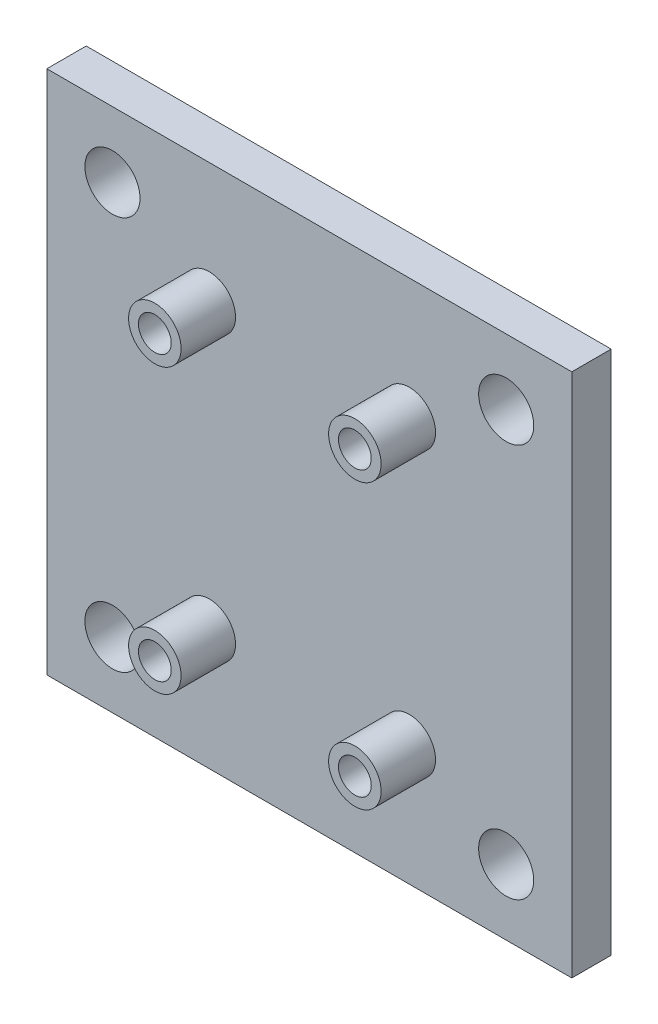
from build123d import *

# Parameters (mm, degrees)
SKETCH_1_W          = 40
SKETCH_1_H          = 40
EXTRUDE_1_DEPTH     = 3
SKETCH_2_R          = 2
EXTRUDE_2_DEPTH     = 4.15
SKETCH_4_R          = 2.1
CUT_EXTRUDE_1_DEPTH = 4
SKETCH_3_R          = 1.25
CUT_EXTRUDE_2_DEPTH = 4.15


with BuildPart() as part:
    # 草圖1 → 填料-伸長1 (new body)
    with BuildSketch(Plane.XY):
        Rectangle(SKETCH_1_W, SKETCH_1_H)
    extrude(amount=EXTRUDE_1_DEPTH)

    # 草圖2 → 填料-伸長2 (add)
    with BuildSketch(Plane.XY.offset(3)):
        with Locations((-7.62, 10.795)):
            Circle(SKETCH_2_R)
        with Locations((-7.62, -10.795)):
            Circle(SKETCH_2_R)
        with Locations((7.62, -10.795)):
            Circle(SKETCH_2_R)
        with Locations((7.62, 10.795)):
            Circle(SKETCH_2_R)
    extrude(amount=EXTRUDE_2_DEPTH)

    # 草圖4 → 除料-伸長1 (cut, through all)
    with BuildSketch(Plane.XY.offset(3)):
        with Locations((-15, 15)):
            Circle(SKETCH_4_R)
        with Locations((-15, -15)):
            Circle(SKETCH_4_R)
        with Locations((15, -15)):
            Circle(SKETCH_4_R)
        with Locations((15, 15)):
            Circle(SKETCH_4_R)
    extrude(amount=-CUT_EXTRUDE_1_DEPTH, mode=Mode.SUBTRACT)

    # 草圖3 → 除料-伸長2 (cut)
    with BuildSketch(Plane.XY.offset(7.15)):
        with Locations((-7.62, 10.795)):
            Circle(SKETCH_3_R)
        with Locations((-7.62, -10.795)):
            Circle(SKETCH_3_R)
        with Locations((7.62, -10.795)):
            Circle(SKETCH_3_R)
        with Locations((7.62, 10.795)):
            Circle(SKETCH_3_R)
    extrude(amount=-CUT_EXTRUDE_2_DEPTH, mode=Mode.SUBTRACT)


solid = part.part
